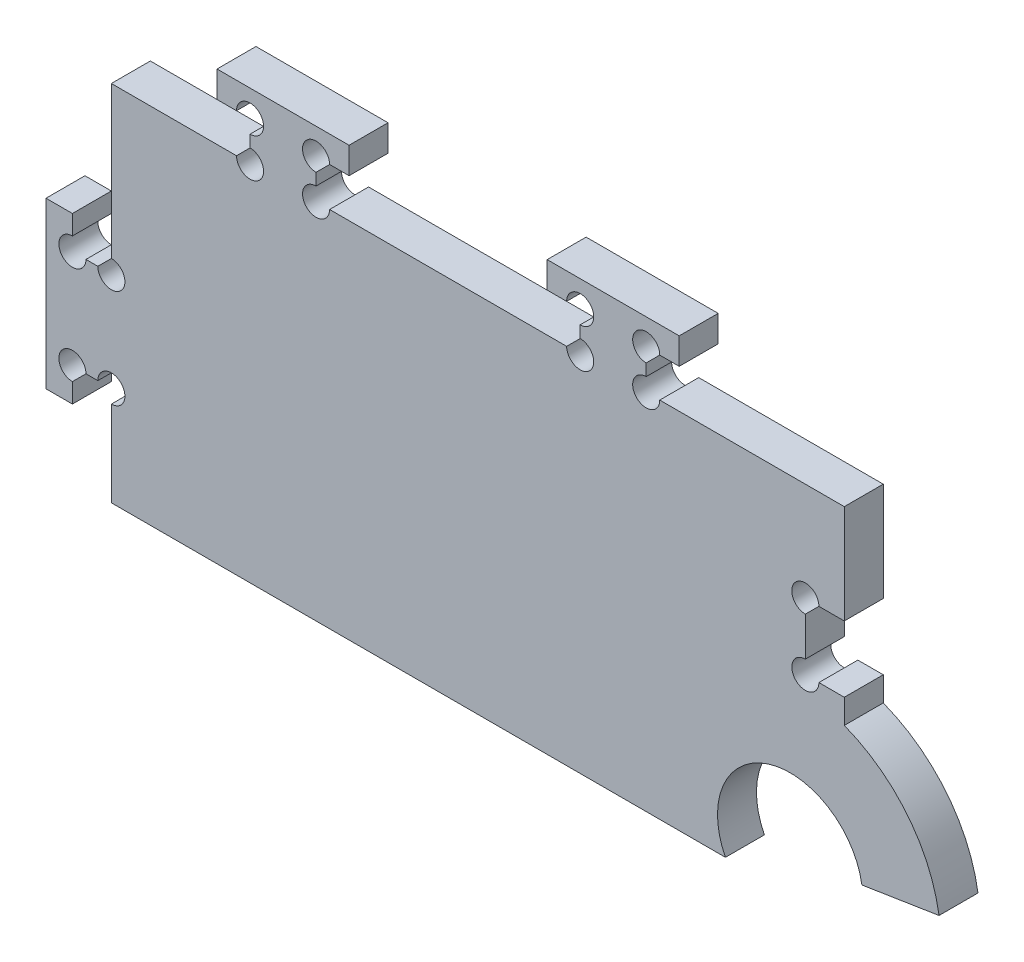
from build123d import *

# Parameters (mm, degrees)
BOSS_EXTRUDE1_DEPTH = 5.9
SKETCH2_W           = 8
SKETCH2_H           = 55
BOSS_EXTRUDE2_DEPTH = 8
SKETCH3_W           = 5.9
SKETCH3_H           = 10
SKETCH3_W_2         = 9
SKETCH3_H_2         = 15
CUT_EXTRUDE1_DEPTH  = 9
BOSS_EXTRUDE3_DEPTH = 5.9
BOSS_EXTRUDE4_DEPTH = 8
SKETCH6_W           = 27.583097586
SKETCH6_H           = 68.456340366
CUT_EXTRUDE2_DEPTH  = 9
BOSS_EXTRUDE5_DEPTH = 5.9
CUT_EXTRUDE3_REACH  = 7.9
SKETCH8_R           = 2.05


with BuildPart() as part:
    # Sketch1 → Boss-Extrude1 (new body)
    with BuildSketch(Plane.XY):
        with BuildLine():
            ThreePointArc((97.061822228, 90.695765473), (82.799132124, 99.447826237), (76.396720763, 83.987165662))
            Line((76.396720763, 83.987165662), (-17.603279237, 83.987165662))
            Line((-17.603279237, 83.987165662), (-17.603279237, 138.987165662))
            Line((-17.603279237, 138.987165662), (94.396720763, 138.987165662))
            Line((94.396720763, 138.987165662), (94.396720763, 110.289306386))
            ThreePointArc((94.396720763, 110.289306386), (103.949970876, 103.334562845), (108.745956392, 92.534953205))
            Line((108.745956392, 92.534953205), (97.061822228, 90.695765473))
        make_face()
    extrude(amount=BOSS_EXTRUDE1_DEPTH)

    # Sketch2 → Boss-Extrude2 (add)
    with BuildSketch(Plane.XY.offset(5.9)):
        with Locations((-21.603279237, 111.487165662)):
            Rectangle(SKETCH2_W, SKETCH2_H)
    extrude(amount=-BOSS_EXTRUDE2_DEPTH)

    # Sketch3 → Cut-Extrude1 (cut, through all)
    with BuildSketch(Plane.XY.offset(5.9)):
        with Locations((91.446720763, 118.987165662)):
            Rectangle(SKETCH3_W, SKETCH3_H)
        with Locations((-21.103279237, 91.487165662)):
            Rectangle(SKETCH3_W_2, SKETCH3_H_2)
    extrude(amount=-CUT_EXTRUDE1_DEPTH, mode=Mode.SUBTRACT)

    # Sketch4 → Boss-Extrude3 (add)
    with BuildSketch(Plane.XY.offset(5.9)):
        Polygon((4.396720763, 138.987165662), (4.396720763, 144.887165662), (-0.603279237, 144.887165662), (-0.603279237, 148.887165662), (19.396720763, 148.887165662), (19.396720763, 144.887165662), (14.396720763, 144.887165662), (14.396720763, 138.987165662), align=None)
        Polygon((49.396720763, 144.887165662), (49.396720763, 148.887165662), (69.396720763, 148.887165662), (69.396720763, 144.887165662), (64.396720763, 144.887165662), (64.396720763, 138.987165662), (54.396720763, 138.987165662), (54.396720763, 144.887165662), align=None)
    extrude(amount=-BOSS_EXTRUDE3_DEPTH)

    # Sketch5 → Boss-Extrude4 (add, through all)
    with BuildSketch(Plane.XY.offset(5.9)):
        Polygon((-25.603279237, 123.987165662), (-33.603279237, 123.987165662), (-33.603279237, 128.987165662), (-37.603279237, 128.987165662), (-37.603279237, 103.987165662), (-33.603279237, 103.987165662), (-33.603279237, 108.987165662), (-25.603279237, 108.987165662), align=None)
    extrude(amount=-BOSS_EXTRUDE4_DEPTH)

    # Sketch6 → Cut-Extrude2 (cut, through all)
    with BuildSketch(Plane.XY.offset(5.9)):
        with Locations((-30.39482803, 118.215335845)):
            Rectangle(SKETCH6_W, SKETCH6_H)
    extrude(amount=-CUT_EXTRUDE2_DEPTH, mode=Mode.SUBTRACT)

    # Sketch7 → Boss-Extrude5 (add)
    with BuildSketch(Plane.XY.offset(5.9)):
        Polygon((-16.603279237, 113.987165662), (-22.503279237, 113.987165662), (-22.503279237, 118.987165662), (-26.503279237, 118.987165662), (-26.503279237, 93.987165662), (-22.503279237, 93.987165662), (-22.503279237, 98.987165662), (-16.603279237, 98.987165662), align=None)
    extrude(amount=-BOSS_EXTRUDE5_DEPTH)

    # Sketch8 → Cut-Extrude3 (cut, up to next)
    with BuildSketch(Plane.XY.offset(5.9), mode=Mode.PRIVATE) as cut_extrude3_sk1:
        with Locations((-16.603279237, 98.987165662)):
            Circle(SKETCH8_R)
    cut_extrude3_tool1 = extrude(cut_extrude3_sk1.sketch, amount=-CUT_EXTRUDE3_REACH, mode=Mode.PRIVATE) & part.part
    add(cut_extrude3_tool1.solids().sort_by_distance((-16.603279, 98.987166, 5.9))[0], mode=Mode.SUBTRACT)
    # Sketch8 → Cut-Extrude3 (cut, up to next)
    with BuildSketch(Plane.XY.offset(5.9), mode=Mode.PRIVATE) as cut_extrude3_sk2:
        with Locations((-22.503279237, 98.987165662)):
            Circle(SKETCH8_R)
    cut_extrude3_tool2 = extrude(cut_extrude3_sk2.sketch, amount=-CUT_EXTRUDE3_REACH, mode=Mode.PRIVATE) & part.part
    add(cut_extrude3_tool2.solids().sort_by_distance((-22.503279, 98.987166, 5.9))[0], mode=Mode.SUBTRACT)
    # Sketch8 → Cut-Extrude3 (cut, up to next)
    with BuildSketch(Plane.XY.offset(5.9), mode=Mode.PRIVATE) as cut_extrude3_sk3:
        with Locations((-22.503279237, 113.987165662)):
            Circle(SKETCH8_R)
    cut_extrude3_tool3 = extrude(cut_extrude3_sk3.sketch, amount=-CUT_EXTRUDE3_REACH, mode=Mode.PRIVATE) & part.part
    add(cut_extrude3_tool3.solids().sort_by_distance((-22.503279, 113.987166, 5.9))[0], mode=Mode.SUBTRACT)
    # Sketch8 → Cut-Extrude3 (cut, up to next)
    with BuildSketch(Plane.XY.offset(5.9), mode=Mode.PRIVATE) as cut_extrude3_sk4:
        with Locations((-16.603279237, 113.987165662)):
            Circle(SKETCH8_R)
    cut_extrude3_tool4 = extrude(cut_extrude3_sk4.sketch, amount=-CUT_EXTRUDE3_REACH, mode=Mode.PRIVATE) & part.part
    add(cut_extrude3_tool4.solids().sort_by_distance((-16.603279, 113.987166, 5.9))[0], mode=Mode.SUBTRACT)
    # Sketch8 → Cut-Extrude3 (cut, up to next)
    with BuildSketch(Plane.XY.offset(5.9), mode=Mode.PRIVATE) as cut_extrude3_sk5:
        with Locations((4.396720763, 138.987165662)):
            Circle(SKETCH8_R)
    cut_extrude3_tool5 = extrude(cut_extrude3_sk5.sketch, amount=-CUT_EXTRUDE3_REACH, mode=Mode.PRIVATE) & part.part
    add(cut_extrude3_tool5.solids().sort_by_distance((4.396721, 138.987166, 5.9))[0], mode=Mode.SUBTRACT)
    # Sketch8 → Cut-Extrude3 (cut, up to next)
    with BuildSketch(Plane.XY.offset(5.9), mode=Mode.PRIVATE) as cut_extrude3_sk6:
        with Locations((14.396720763, 138.987165662)):
            Circle(SKETCH8_R)
    cut_extrude3_tool6 = extrude(cut_extrude3_sk6.sketch, amount=-CUT_EXTRUDE3_REACH, mode=Mode.PRIVATE) & part.part
    add(cut_extrude3_tool6.solids().sort_by_distance((14.396721, 138.987166, 5.9))[0], mode=Mode.SUBTRACT)
    # Sketch8 → Cut-Extrude3 (cut, up to next)
    with BuildSketch(Plane.XY.offset(5.9), mode=Mode.PRIVATE) as cut_extrude3_sk7:
        with Locations((14.396720763, 144.887165662)):
            Circle(SKETCH8_R)
    cut_extrude3_tool7 = extrude(cut_extrude3_sk7.sketch, amount=-CUT_EXTRUDE3_REACH, mode=Mode.PRIVATE) & part.part
    add(cut_extrude3_tool7.solids().sort_by_distance((14.396721, 144.887166, 5.9))[0], mode=Mode.SUBTRACT)
    # Sketch8 → Cut-Extrude3 (cut, up to next)
    with BuildSketch(Plane.XY.offset(5.9), mode=Mode.PRIVATE) as cut_extrude3_sk8:
        with Locations((4.396720763, 144.887165662)):
            Circle(SKETCH8_R)
    cut_extrude3_tool8 = extrude(cut_extrude3_sk8.sketch, amount=-CUT_EXTRUDE3_REACH, mode=Mode.PRIVATE) & part.part
    add(cut_extrude3_tool8.solids().sort_by_distance((4.396721, 144.887166, 5.9))[0], mode=Mode.SUBTRACT)
    # Sketch8 → Cut-Extrude3 (cut, up to next)
    with BuildSketch(Plane.XY.offset(5.9), mode=Mode.PRIVATE) as cut_extrude3_sk9:
        with Locations((54.396720763, 144.887165662)):
            Circle(SKETCH8_R)
    cut_extrude3_tool9 = extrude(cut_extrude3_sk9.sketch, amount=-CUT_EXTRUDE3_REACH, mode=Mode.PRIVATE) & part.part
    add(cut_extrude3_tool9.solids().sort_by_distance((54.396721, 144.887166, 5.9))[0], mode=Mode.SUBTRACT)
    # Sketch8 → Cut-Extrude3 (cut, up to next)
    with BuildSketch(Plane.XY.offset(5.9), mode=Mode.PRIVATE) as cut_extrude3_sk10:
        with Locations((54.396720763, 138.987165662)):
            Circle(SKETCH8_R)
    cut_extrude3_tool10 = extrude(cut_extrude3_sk10.sketch, amount=-CUT_EXTRUDE3_REACH, mode=Mode.PRIVATE) & part.part
    add(cut_extrude3_tool10.solids().sort_by_distance((54.396721, 138.987166, 5.9))[0], mode=Mode.SUBTRACT)
    # Sketch8 → Cut-Extrude3 (cut, up to next)
    with BuildSketch(Plane.XY.offset(5.9), mode=Mode.PRIVATE) as cut_extrude3_sk11:
        with Locations((64.396720763, 138.987165662)):
            Circle(SKETCH8_R)
    cut_extrude3_tool11 = extrude(cut_extrude3_sk11.sketch, amount=-CUT_EXTRUDE3_REACH, mode=Mode.PRIVATE) & part.part
    add(cut_extrude3_tool11.solids().sort_by_distance((64.396721, 138.987166, 5.9))[0], mode=Mode.SUBTRACT)
    # Sketch8 → Cut-Extrude3 (cut, up to next)
    with BuildSketch(Plane.XY.offset(5.9), mode=Mode.PRIVATE) as cut_extrude3_sk12:
        with Locations((64.396720763, 144.887165662)):
            Circle(SKETCH8_R)
    cut_extrude3_tool12 = extrude(cut_extrude3_sk12.sketch, amount=-CUT_EXTRUDE3_REACH, mode=Mode.PRIVATE) & part.part
    add(cut_extrude3_tool12.solids().sort_by_distance((64.396721, 144.887166, 5.9))[0], mode=Mode.SUBTRACT)
    # Sketch8 → Cut-Extrude3 (cut, up to next)
    with BuildSketch(Plane.XY.offset(5.9), mode=Mode.PRIVATE) as cut_extrude3_sk13:
        with Locations((88.496720763, 123.987165662)):
            Circle(SKETCH8_R)
    cut_extrude3_tool13 = extrude(cut_extrude3_sk13.sketch, amount=-CUT_EXTRUDE3_REACH, mode=Mode.PRIVATE) & part.part
    add(cut_extrude3_tool13.solids().sort_by_distance((88.496721, 123.987166, 5.9))[0], mode=Mode.SUBTRACT)
    # Sketch8 → Cut-Extrude3 (cut, up to next)
    with BuildSketch(Plane.XY.offset(5.9), mode=Mode.PRIVATE) as cut_extrude3_sk14:
        with Locations((88.496720763, 113.987165662)):
            Circle(SKETCH8_R)
    cut_extrude3_tool14 = extrude(cut_extrude3_sk14.sketch, amount=-CUT_EXTRUDE3_REACH, mode=Mode.PRIVATE) & part.part
    add(cut_extrude3_tool14.solids().sort_by_distance((88.496721, 113.987166, 5.9))[0], mode=Mode.SUBTRACT)


solid = part.part
